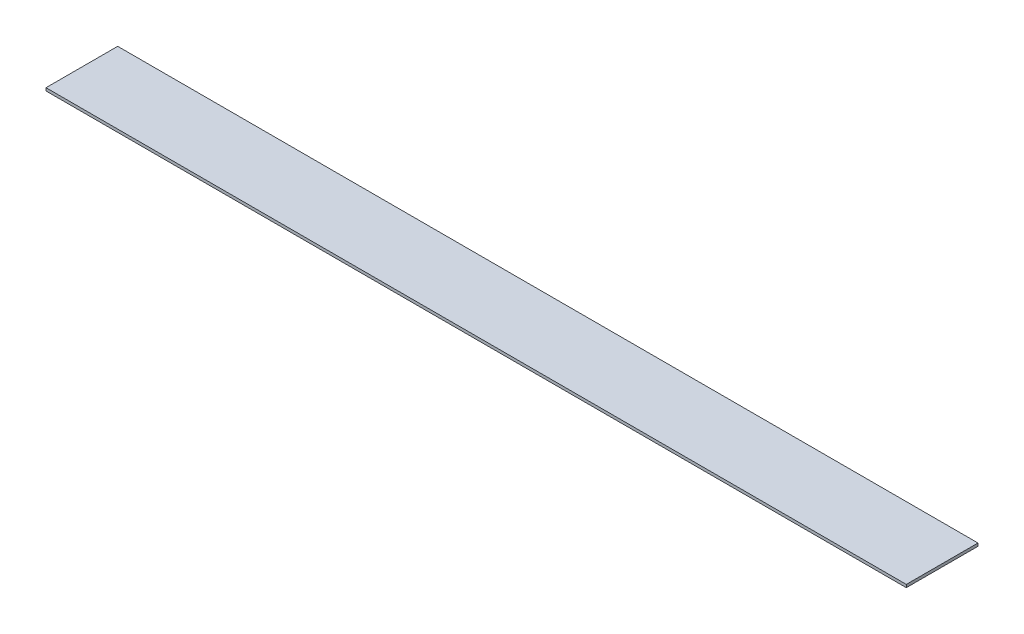
from build123d import *

# Parameters (mm, degrees)
SKETCH1_W           = 300
SKETCH1_H           = 25
BOSS_EXTRUDE1_DEPTH = 1


with BuildPart() as part:
    # Sketch1 → Boss-Extrude1 (new body)
    with BuildSketch(Plane(origin=(0, 0, 0), x_dir=(1, 0, 0), z_dir=(0, 1, 0))):
        Rectangle(SKETCH1_W, SKETCH1_H)
    extrude(amount=BOSS_EXTRUDE1_DEPTH)


solid = part.part
